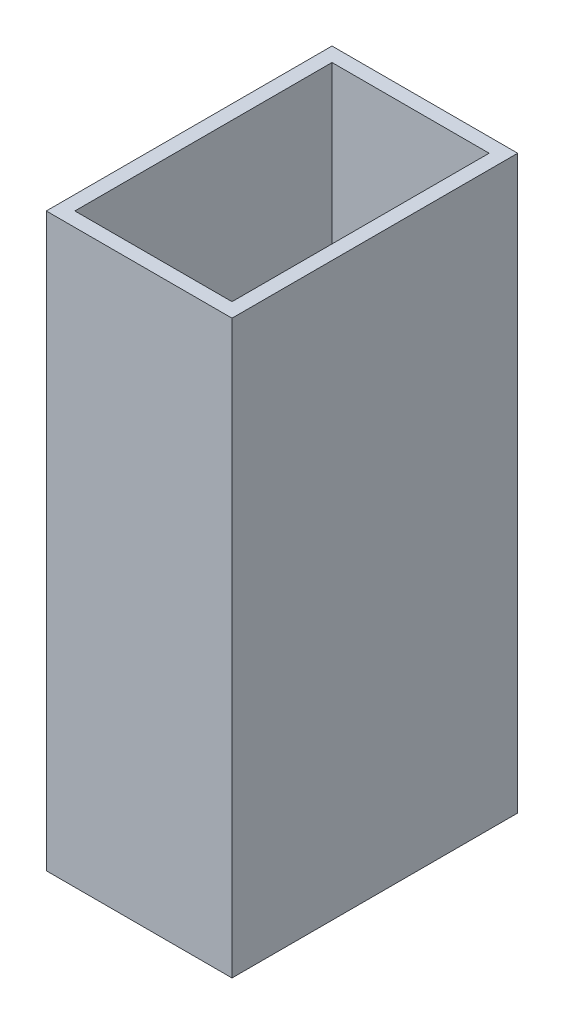
from build123d import *

# Parameters (mm, degrees)
SKETCH1_W           = 65
SKETCH1_H           = 100
BOSS_EXTRUDE1_DEPTH = 200
SHELL1_T            = -5


with BuildPart() as part:
    # Sketch1 → Boss-Extrude1 (new body)
    with BuildSketch(Plane(origin=(0, 0, 0), x_dir=(1, 0, 0), z_dir=(0, 1, 0))):
        Rectangle(SKETCH1_W, SKETCH1_H)
    extrude(amount=BOSS_EXTRUDE1_DEPTH)

    # Shell1
    shell1_openings = [part.faces().sort_by_distance(p)[0] for p in [
        (0, 200, 0),
    ]]
    offset(amount=SHELL1_T, openings=shell1_openings, kind=Kind.INTERSECTION)


solid = part.part
